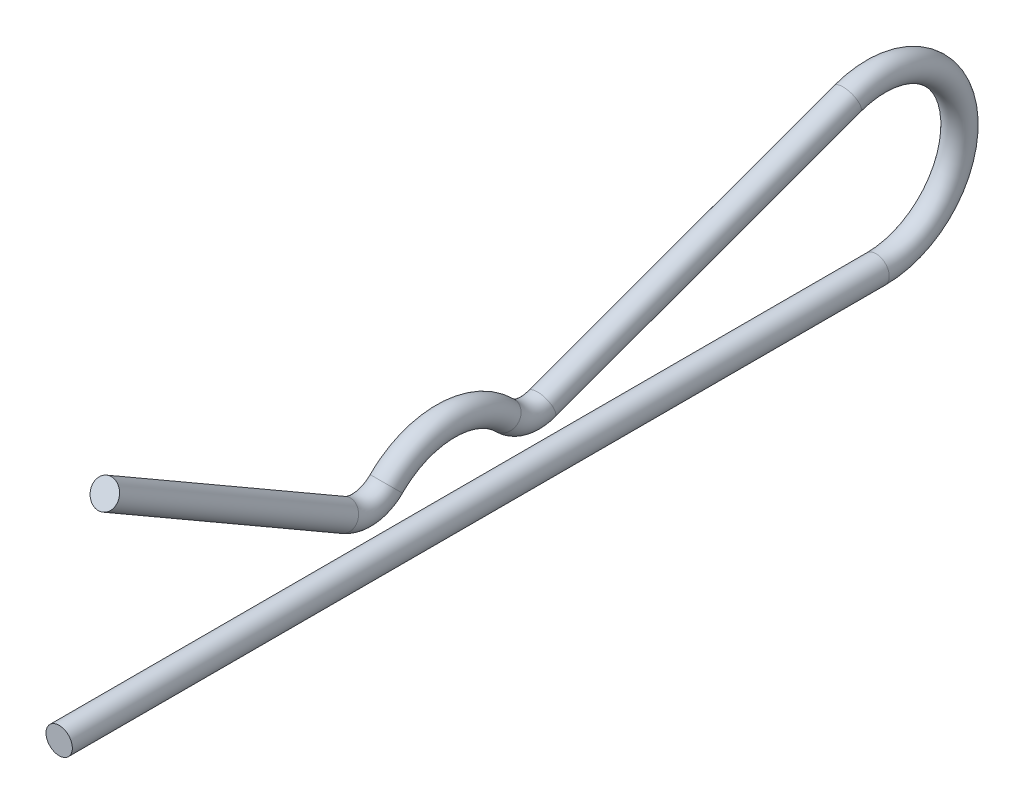
from build123d import *

# Parameters (mm, degrees)
SKETCH1_R = 0.5953125


with BuildPart() as part:
    # Sweep1: sweep along a path in Sketch2
    with BuildLine(Plane(origin=(0, 0, 0), x_dir=(0, 0, -1), z_dir=(1, 0, 0))) as sweep1_path:
        Line((0, 0), (36.909375, 0))
        ThreePointArc((36.909375, 0), (40.622217262, 4.426101099), (35.617789953, 7.312496066))
        Line((35.617789953, 7.312496066), (21.813016555, 2.278866788))
        ThreePointArc((21.813016555, 2.278866788), (20.922324668, 2.221170864), (20.141282747, 2.65318287))
        ThreePointArc((20.141282747, 2.65318287), (17.4625, 3.7703125), (14.783717253, 2.65318287))
        ThreePointArc((14.783717253, 2.65318287), (13.866796784, 2.196895743), (12.862058728, 2.395497171))
        Line((12.862058728, 2.395497171), (2.06375, 8.629903623))
    # Sketch1 → Sweep1 (sweep)
    with BuildSketch(Plane.XY):
        Circle(SKETCH1_R)
    sweep(path=sweep1_path.line)


solid = part.part
